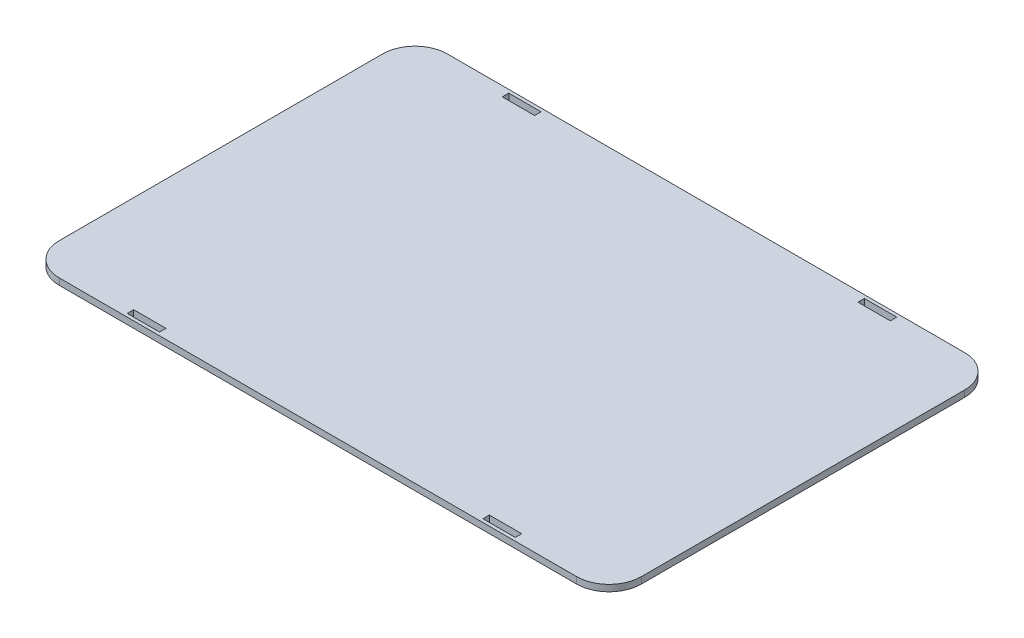
from build123d import *

# Parameters (mm, degrees)
SKETCH1_W           = 180
SKETCH1_H           = 120
BOSS_EXTRUDE1_DEPTH = 2
FILLET1_R           = 10
FILLET2_R           = 10
FILLET3_R           = 10
FILLET4_R           = 10
SKETCH3_W           = 10
SKETCH3_H           = 2
CUT_EXTRUDE1_DEPTH  = 7


with BuildPart() as part:
    # Sketch1 → Boss-Extrude1 (new body)
    with BuildSketch(Plane(origin=(0, 0, 0), x_dir=(1, 0, 0), z_dir=(0, 1, 0))):
        Rectangle(SKETCH1_W, SKETCH1_H)
    extrude(amount=BOSS_EXTRUDE1_DEPTH)

    # Fillet1
    fillet1_edges = [part.edges().sort_by_distance(p)[0] for p in [
        (-90, 1, 60),
    ]]
    fillet(fillet1_edges, radius=FILLET1_R)

    # Fillet2
    fillet2_edges = [part.edges().sort_by_distance(p)[0] for p in [
        (-90, 1, -60),
    ]]
    fillet(fillet2_edges, radius=FILLET2_R)

    # Fillet3
    fillet3_edges = [part.edges().sort_by_distance(p)[0] for p in [
        (90, 1, 60),
    ]]
    fillet(fillet3_edges, radius=FILLET3_R)

    # Fillet4
    fillet4_edges = [part.edges().sort_by_distance(p)[0] for p in [
        (90, 1, -60),
    ]]
    fillet(fillet4_edges, radius=FILLET4_R)

    # Sketch3 → Cut-Extrude1 (cut)
    with BuildSketch(Plane(origin=(0, 0, 0), x_dir=(1, 0, 0), z_dir=(0, 1, 0))):
        with Locations((-55, 58)):
            Rectangle(SKETCH3_W, SKETCH3_H)
        with Locations((55, 58)):
            Rectangle(SKETCH3_W, SKETCH3_H)
        with Locations((-55, -58)):
            Rectangle(SKETCH3_W, SKETCH3_H)
        with Locations((55, -58)):
            Rectangle(SKETCH3_W, SKETCH3_H)
    extrude(amount=CUT_EXTRUDE1_DEPTH, mode=Mode.SUBTRACT)


solid = part.part
